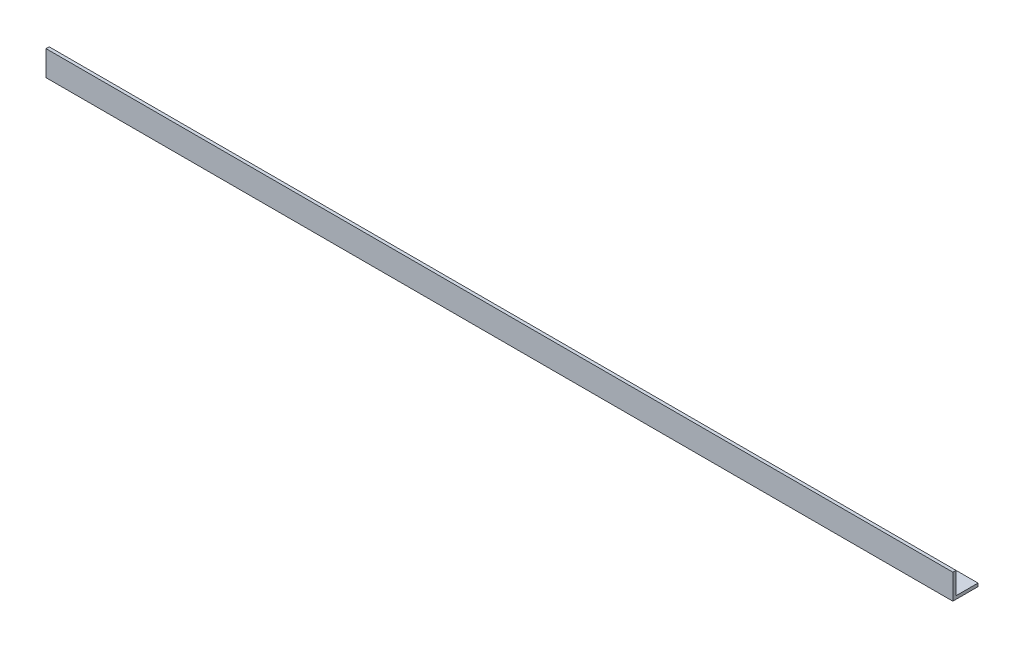
from build123d import *

# Parameters (mm, degrees)
BOSS_EXTRUDE1_DEPTH = 457.2


with BuildPart() as part:
    # Sketch1 → Boss-Extrude1 (new body, symmetric)
    with BuildSketch(Plane(origin=(0, 0, 0), x_dir=(0, 0, -1), z_dir=(1, 0, 0))):
        Polygon((0, 0), (0, 25.4), (3.175, 25.4), (3.175, 3.175), (25.4, 3.175), (25.4, 0), align=None)
    extrude(amount=BOSS_EXTRUDE1_DEPTH, both=True)


solid = part.part
